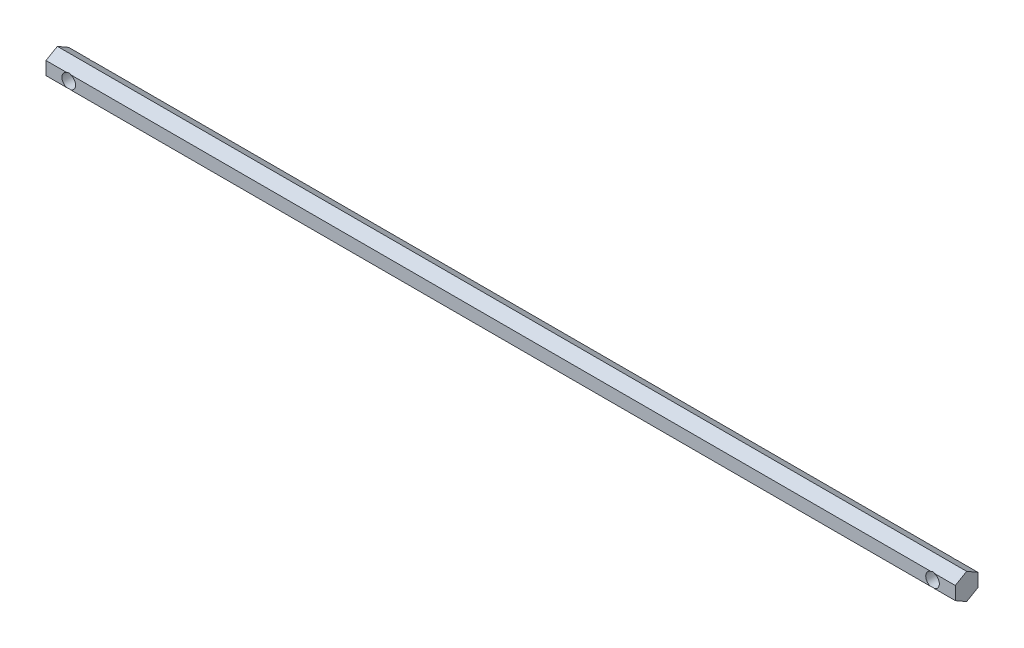
from build123d import *

# Parameters (mm, degrees)
BOSS_EXTRUDE1_DEPTH     = 200
SKETCH2_R               = 3
CUT_EXTRUDE1_DEPTH      = 6
CUT_EXTRUDE1_DEPTH_BACK = 6


with BuildPart() as part:
    # Sketch1 → Boss-Extrude1 (new body, symmetric)
    with BuildSketch(Plane(origin=(0, 0, 0), x_dir=(0, 0, -1), z_dir=(1, 0, 0))):
        Polygon((0, 5.773502692), (-5, 2.886751346), (-5, -2.886751346), (0, -5.773502692), (5, -2.886751346), (5, 2.886751346), align=None)
    extrude(amount=BOSS_EXTRUDE1_DEPTH, both=True)

    # Sketch2 → Cut-Extrude1 (cut, two sides)
    with BuildSketch(Plane.XY) as cut_extrude1_sk:
        with Locations((190, 0)):
            Circle(SKETCH2_R)
        with Locations((-190, 0)):
            Circle(SKETCH2_R)
    extrude(amount=CUT_EXTRUDE1_DEPTH, mode=Mode.SUBTRACT)
    extrude(cut_extrude1_sk.sketch, amount=-CUT_EXTRUDE1_DEPTH_BACK, mode=Mode.SUBTRACT)


solid = part.part
